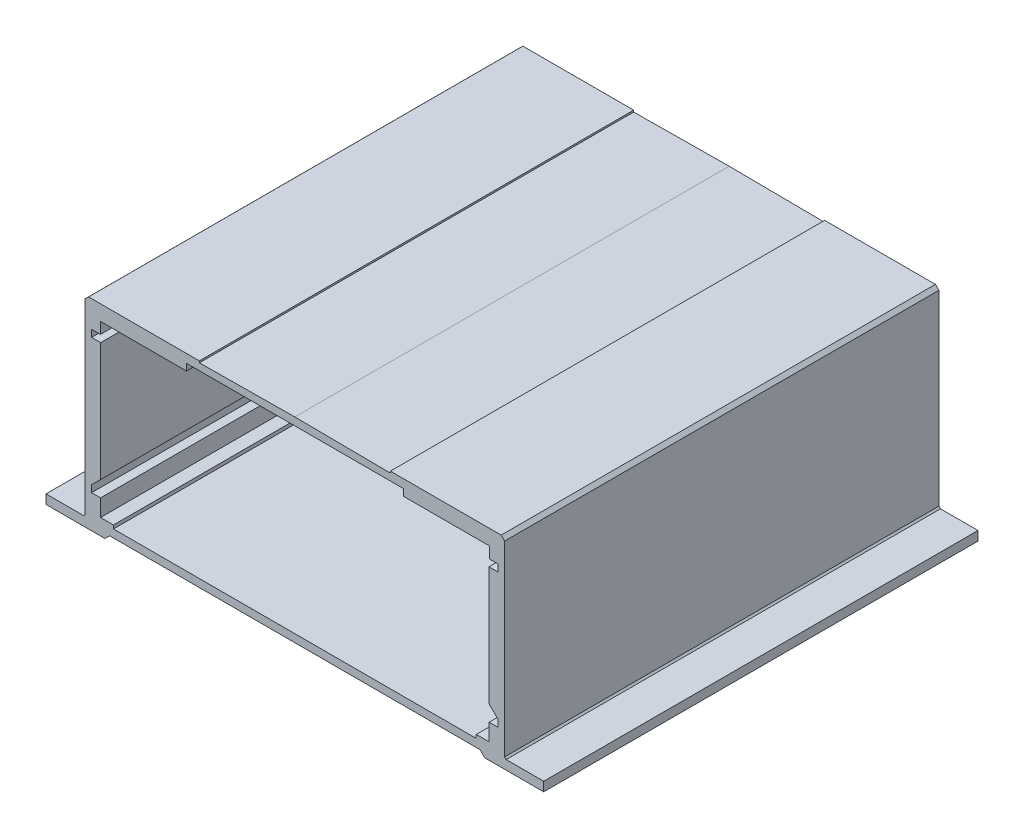
from build123d import *

# Parameters (mm, degrees)
BOSS_EXTRUDE1_DEPTH = 100


with BuildPart() as part:
    # Sketch1 → Boss-Extrude1 (new body)
    with BuildSketch(Plane.XY):
        Polygon((-42.640501462, 0), (0, 0), (0, 1.805938608), (-41.76781617, 1.805938608), (-41.76781617, 2.603006823), (-44.734392464, 2.603006823), (-44.734392464, 6.522673981), (-46.8, 6.522673981), (-46.8, 8.122673981), (-44.7, 10.188281516), (-44.7, 37.494976181), (-46.8, 37.494976181), (-46.8, 39.094976181), (-44.767698794, 39.094976181), (-44.767698794, 41.705938608), (-24.973882416, 41.705938608), (-24.973882416, 43.24560851), (0, 43.24560851), (0, 45.023153475), (-21.988241511, 44.824503247), (-21.988241511, 45.21521639), (-47.498865937, 45.21521639), (-48.3, 44.427202791), (-48.3, 1.384902814), (-48.656798132, 1.033948095), (-57.3, 1.033948095), (-57.3, -1.08478361), (-43.743346771, -1.08478361), align=None)
        Polygon((0, 0), (42.640501462, 0), (43.743346771, -1.08478361), (57.3, -1.08478361), (57.3, 1.033948095), (48.656798132, 1.033948095), (48.3, 1.384902814), (48.3, 44.427202791), (47.498865937, 45.21521639), (21.988241511, 45.21521639), (21.988241511, 44.824503247), (0, 45.023153475), (0, 43.24560851), (24.973882416, 43.24560851), (24.973882416, 41.705938608), (44.767698794, 41.705938608), (44.767698794, 39.094976181), (46.8, 39.094976181), (46.8, 37.494976181), (44.7, 37.494976181), (44.7, 10.188281516), (46.8, 8.122673981), (46.8, 6.522673981), (44.734392464, 6.522673981), (44.734392464, 2.603006823), (41.76781617, 2.603006823), (41.76781617, 1.805938608), (0, 1.805938608), align=None)
    extrude(amount=BOSS_EXTRUDE1_DEPTH)


solid = part.part
